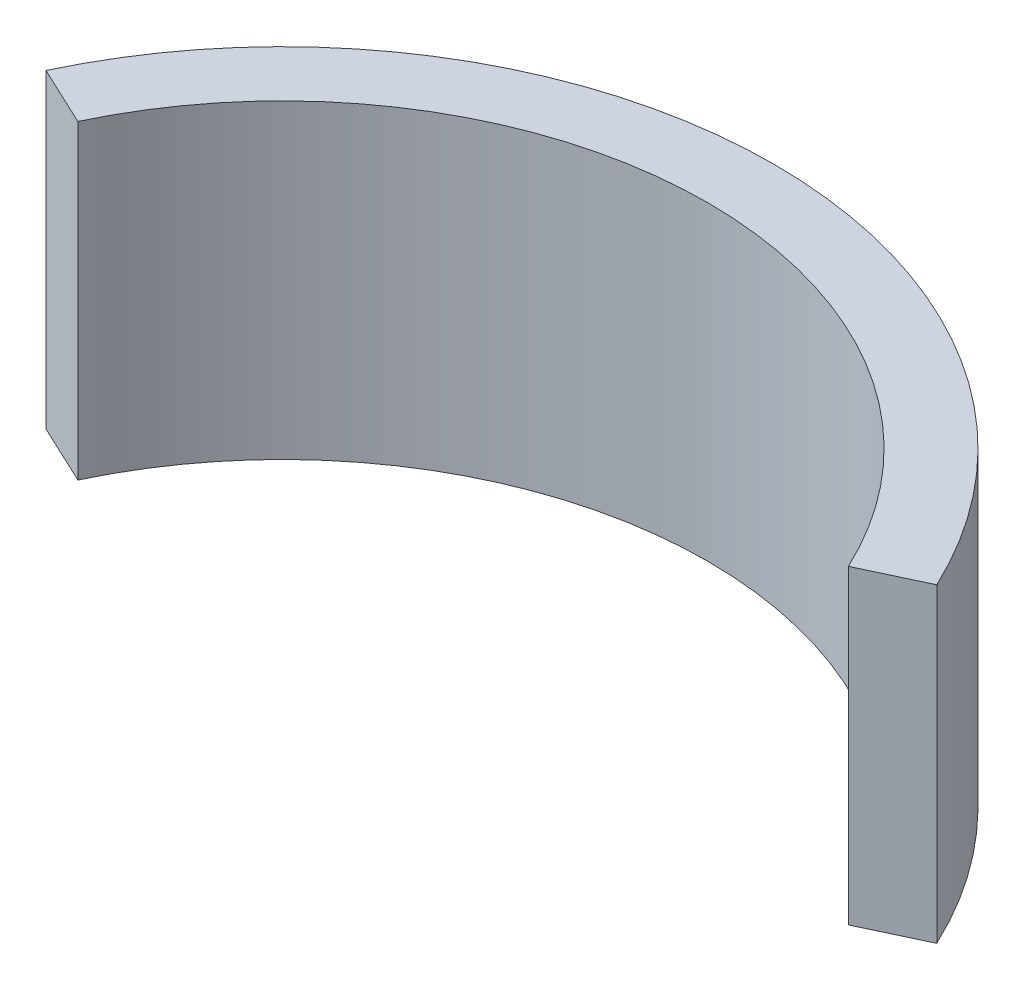
from build123d import *

# Parameters (mm, degrees)
BOSS_EXTRUDE1_DEPTH = 6.08


with BuildPart() as part:
    # Sketch1 → Boss-Extrude1 (new body)
    with BuildSketch(Plane(origin=(0, 0, 0), x_dir=(1, 0, 0), z_dir=(0, 1, 0))):
        with BuildLine():
            Line((7.543281251, -6.089420645), (8.719797823, -5.536420865))
            ThreePointArc((8.719797823, -5.536420865), (0, 0), (-8.719797823, -5.536420865))
            Line((-8.719797823, -5.536420865), (-7.543281251, -6.089420645))
            ThreePointArc((-7.543281251, -6.089420645), (0, -1.3), (7.543281251, -6.089420645))
        make_face()
    extrude(amount=BOSS_EXTRUDE1_DEPTH)


solid = part.part
